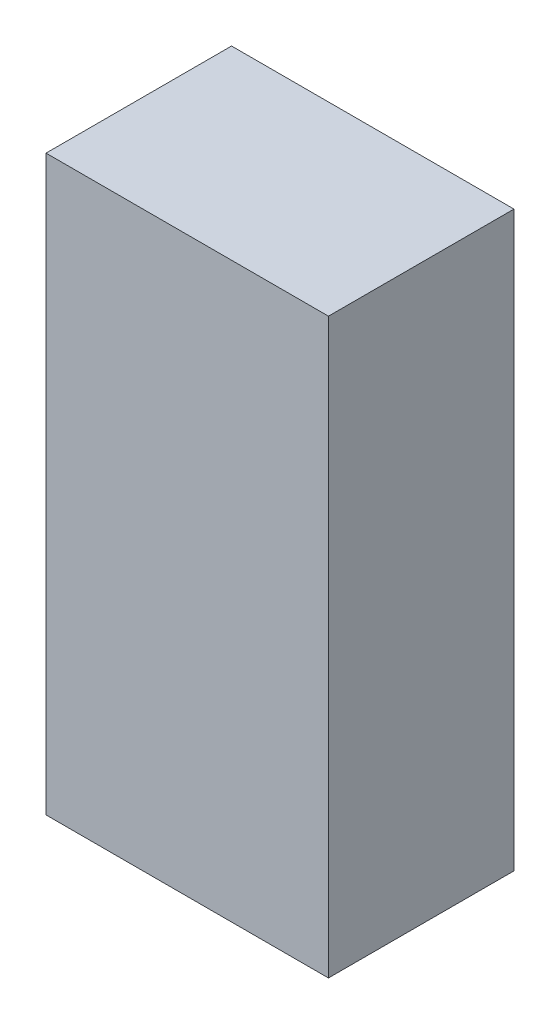
from build123d import *

# Parameters (mm, degrees)
SKETCH1_W           = 25.908
SKETCH1_H           = 17.018
BOSS_EXTRUDE1_DEPTH = 52.578


with BuildPart() as part:
    # Sketch1 → Boss-Extrude1 (new body)
    with BuildSketch(Plane(origin=(0, 0, 0), x_dir=(1, 0, 0), z_dir=(0, 1, 0))):
        Rectangle(SKETCH1_W, SKETCH1_H)
    extrude(amount=BOSS_EXTRUDE1_DEPTH)


solid = part.part
